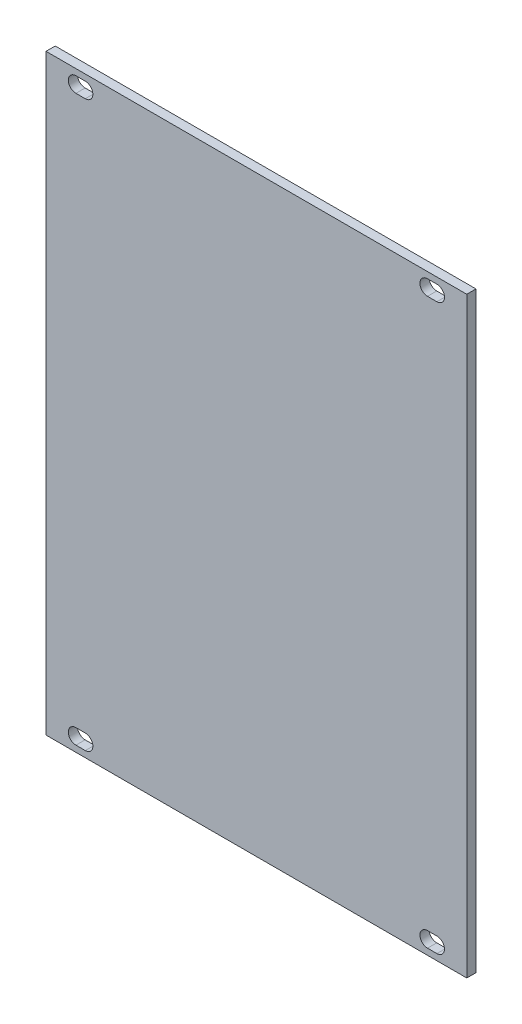
from build123d import *

# Parameters (mm, degrees)
SKETCH1_W           = 91.3
SKETCH1_H           = 128.5
BOSS_EXTRUDE1_DEPTH = 2


with BuildPart() as part:
    # Sketch1 → Boss-Extrude1 (new body)
    with BuildSketch(Plane.XY):
        Rectangle(SKETCH1_W, SKETCH1_H)
        with BuildLine():
            Line((-39.166, -59.6), (-37.134, -59.6))
            ThreePointArc((-37.134, -59.6), (-35.484, -61.25), (-37.134, -62.9))
            Line((-37.134, -62.9), (-39.166, -62.9))
            ThreePointArc((-39.166, -62.9), (-40.816, -61.25), (-39.166, -59.6))
        make_face(mode=Mode.SUBTRACT)
        with BuildLine():
            Line((-39.166, 62.9), (-37.134, 62.9))
            ThreePointArc((-37.134, 62.9), (-35.484, 61.25), (-37.134, 59.6))
            Line((-37.134, 59.6), (-39.166, 59.6))
            ThreePointArc((-39.166, 59.6), (-40.816, 61.25), (-39.166, 62.9))
        make_face(mode=Mode.SUBTRACT)
        with BuildLine():
            Line((37.134000014, 62.9), (39.166000014, 62.9))
            ThreePointArc((39.166000014, 62.9), (40.816000014, 61.25), (39.166000014, 59.6))
            Line((39.166000014, 59.6), (37.134000014, 59.6))
            ThreePointArc((37.134000014, 59.6), (35.484000014, 61.25), (37.134000014, 62.9))
        make_face(mode=Mode.SUBTRACT)
        with BuildLine():
            Line((37.134000014, -59.6), (39.166000014, -59.6))
            ThreePointArc((39.166000014, -59.6), (40.816000014, -61.25), (39.166000014, -62.9))
            Line((39.166000014, -62.9), (37.134000014, -62.9))
            ThreePointArc((37.134000014, -62.9), (35.484000014, -61.25), (37.134000014, -59.6))
        make_face(mode=Mode.SUBTRACT)
    extrude(amount=BOSS_EXTRUDE1_DEPTH)


solid = part.part
